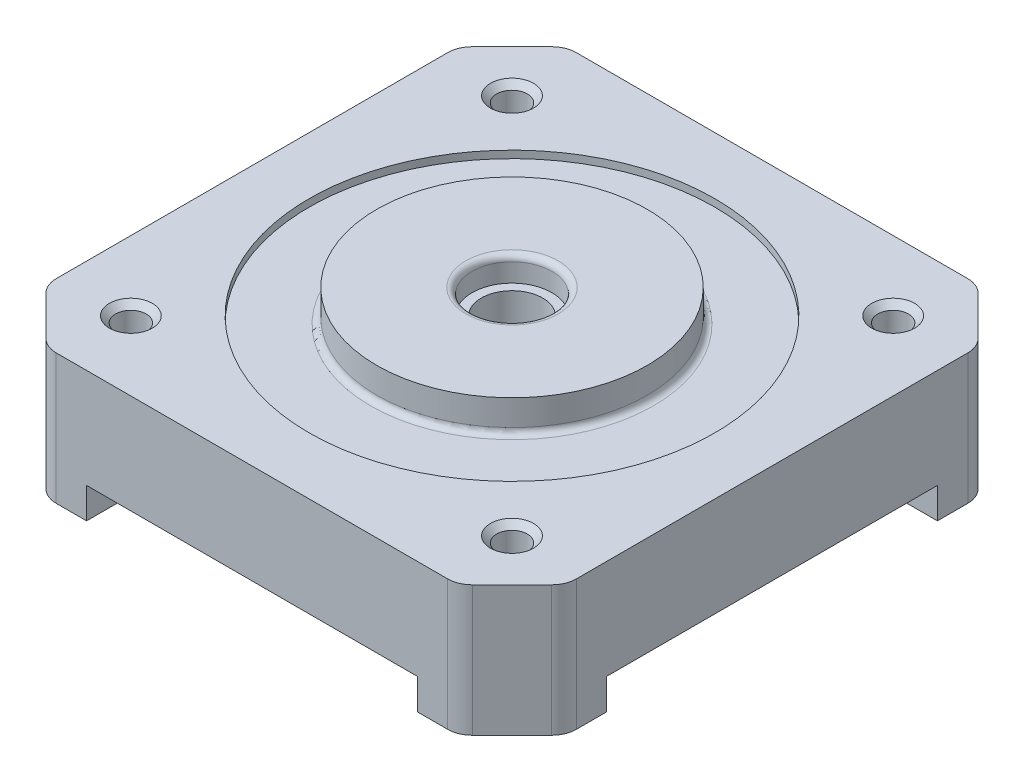
from build123d import *

# Parameters (mm, degrees)
BOSS_EXTRUDE1_DEPTH             = 10.6
SKETCH2_R                       = 16.5
CUT_EXTRUDE1_DEPTH              = 0.6
SKETCH3_R                       = 11
BOSS_EXTRUDE2_DEPTH             = 2.6
SKETCH4_R                       = 3.25
CUT_EXTRUDE2_DEPTH              = 2
SKETCH5_R                       = 2.5
CUT_EXTRUDE3_DEPTH              = 11.6
FILLET1_R                       = 0.5
FILLET2_R                       = 0.5
M3X0_5_TAPPED_HOLE1_D           = 2.5
M3X0_5_TAPPED_HOLE1_DEPTH       = 10
M3X0_5_TAPPED_HOLE1_CSINK_D     = 3.5
M3X0_5_TAPPED_HOLE1_CSINK_ANGLE = 90
M3X0_5_TAPPED_HOLE1_TIP         = 0.751075774
SKETCH10_W                      = 26.901846944
SKETCH10_H                      = 2.5
CUT_EXTRUDE4_DEPTH              = 43.3
SKETCH11_W                      = 26.901846944
SKETCH11_H                      = 2.5
CUT_EXTRUDE5_DEPTH              = 43.3
FILLET3_R                       = 2


with BuildPart() as part:
    # Sketch1 → Boss-Extrude1 (new body)
    with BuildSketch(Plane(origin=(0, 0, 0), x_dir=(1, 0, 0), z_dir=(0, 1, 0))):
        Polygon((-21.15, 16.750923472), (-16.750923472, 21.15), (16.750923472, 21.15), (21.15, 16.750923472), (21.15, -16.750923472), (16.750923472, -21.15), (-16.750923472, -21.15), (-21.15, -16.750923472), align=None)
    extrude(amount=BOSS_EXTRUDE1_DEPTH)

    # Sketch2 → Cut-Extrude1 (cut)
    with BuildSketch(Plane(origin=(0, 10.6, 0), x_dir=(1, 0, 0), z_dir=(0, 1, 0))):
        Circle(SKETCH2_R)
    extrude(amount=-CUT_EXTRUDE1_DEPTH, mode=Mode.SUBTRACT)

    # Sketch3 → Boss-Extrude2 (add)
    with BuildSketch(Plane(origin=(0, 10, 0), x_dir=(1, 0, 0), z_dir=(0, 1, 0))):
        Circle(SKETCH3_R)
    extrude(amount=BOSS_EXTRUDE2_DEPTH)

    # Sketch4 → Cut-Extrude2 (cut)
    with BuildSketch(Plane(origin=(0, 12.6, 0), x_dir=(1, 0, 0), z_dir=(0, 1, 0))):
        Circle(SKETCH4_R)
    extrude(amount=-CUT_EXTRUDE2_DEPTH, mode=Mode.SUBTRACT)

    # Sketch5 → Cut-Extrude3 (cut, through all)
    with BuildSketch(Plane(origin=(0, 10.6, 0), x_dir=(1, 0, 0), z_dir=(0, 1, 0))):
        Circle(SKETCH5_R)
    extrude(amount=-CUT_EXTRUDE3_DEPTH, mode=Mode.SUBTRACT)

    # Fillet1
    fillet1_edges = [part.edges().sort_by_distance(p)[0] for p in [
        (-3.25, 12.6, 0),
    ]]
    fillet(fillet1_edges, radius=FILLET1_R)

    # Fillet2
    fillet2_edges = [part.edges().sort_by_distance(p)[0] for p in [
        (-11, 10, 0),
    ]]
    fillet(fillet2_edges, radius=FILLET2_R)

    # M3x0.5 Tapped Hole1
    with Locations(Plane(origin=(0, 10.6, 0), x_dir=(1, 0, 0), z_dir=(0, 1, 0))):
        with Locations((-15.5, 15.5), (15.5, 15.5), (15.5, -15.5), (-15.5, -15.5)):
            CounterSinkHole(M3X0_5_TAPPED_HOLE1_D / 2, M3X0_5_TAPPED_HOLE1_CSINK_D / 2, depth=M3X0_5_TAPPED_HOLE1_DEPTH, counter_sink_angle=M3X0_5_TAPPED_HOLE1_CSINK_ANGLE)
            with Locations((0, 0, -(M3X0_5_TAPPED_HOLE1_DEPTH + M3X0_5_TAPPED_HOLE1_TIP / 2))):  # 118° drill point
                Cone(0, M3X0_5_TAPPED_HOLE1_D / 2, M3X0_5_TAPPED_HOLE1_TIP, mode=Mode.SUBTRACT)

    # Sketch10 → Cut-Extrude4 (cut, through all)
    with BuildSketch(Plane.XY.offset(21.15)):
        with Locations((0, 1.25)):
            Rectangle(SKETCH10_W, SKETCH10_H)
    extrude(amount=-CUT_EXTRUDE4_DEPTH, mode=Mode.SUBTRACT)

    # Sketch11 → Cut-Extrude5 (cut, through all)
    with BuildSketch(Plane.ZY.offset(21.15)):
        with Locations((0, 1.25)):
            Rectangle(SKETCH11_W, SKETCH11_H)
    extrude(amount=-CUT_EXTRUDE5_DEPTH, mode=Mode.SUBTRACT)

    # Fillet3
    fillet3_edges = [part.edges().sort_by_distance(p)[0] for p in [
        (-21.15, 5.3, -16.750923472),
        (-16.750923472, 5.3, -21.15),
        (16.750923472, 5.3, -21.15),
        (21.15, 5.3, -16.750923472),
        (21.15, 5.3, 16.750923472),
        (16.750923472, 5.3, 21.15),
        (-16.750923472, 5.3, 21.15),
        (-21.15, 5.3, 16.750923472),
    ]]
    fillet(fillet3_edges, radius=FILLET3_R)


solid = part.part
